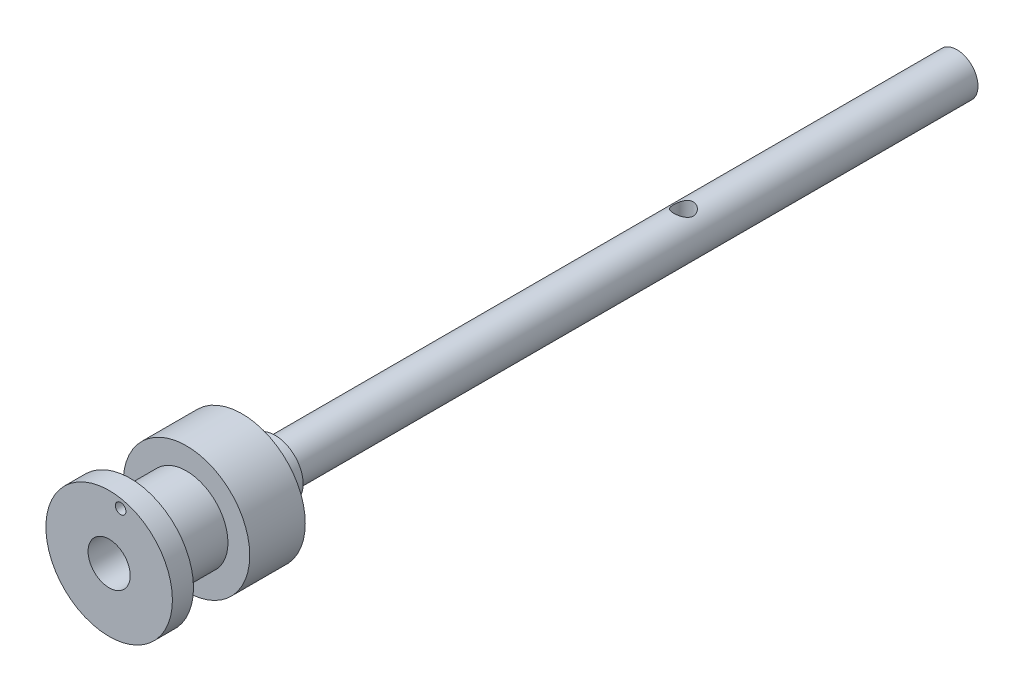
from build123d import *

# Parameters (mm, degrees)
SKETCH1_R               = 3
BOSS_EXTRUDE1_DEPTH     = 97
SKETCH2_R               = 4
BOSS_EXTRUDE2_DEPTH     = 4.7
SKETCH3_R               = 9
BOSS_EXTRUDE3_DEPTH     = 7.9
SKETCH4_R               = 5.9
BOSS_EXTRUDE4_DEPTH     = 8
SKETCH5_R               = 9
BOSS_EXTRUDE5_DEPTH     = 3
CUT_EXTRUDE1_DEPTH      = 82
CUT_EXTRUDE1_DEPTH_BACK = 82
SKETCH6_R               = 1.4
CUT_EXTRUDE2_START      = -9
SKETCH7_R               = 3
SKETCH7_R_2             = 0.75
CUT_EXTRUDE2_DEPTH      = 9


with BuildPart() as part:
    # Sketch1 → Boss-Extrude1 (new body)
    with BuildSketch(Plane.XY):
        Circle(SKETCH1_R)
    extrude(amount=BOSS_EXTRUDE1_DEPTH)

    # Sketch2 → Boss-Extrude2 (add)
    with BuildSketch(Plane.XY.offset(97)):
        Circle(SKETCH2_R)
    extrude(amount=BOSS_EXTRUDE2_DEPTH)

    # Sketch3 → Boss-Extrude3 (add)
    with BuildSketch(Plane.XY.offset(101.7)):
        Circle(SKETCH3_R)
    extrude(amount=BOSS_EXTRUDE3_DEPTH)

    # Sketch4 → Boss-Extrude4 (add)
    with BuildSketch(Plane.XY.offset(109.6)):
        Circle(SKETCH4_R)
    extrude(amount=BOSS_EXTRUDE4_DEPTH)

    # Sketch5 → Boss-Extrude5 (add)
    with BuildSketch(Plane.XY.offset(117.6)):
        Circle(SKETCH5_R)
    extrude(amount=BOSS_EXTRUDE5_DEPTH)

    # Sketch6 → Cut-Extrude1 (cut, two sides: drawn at the far end of the back side and taken through both)
    with BuildSketch(Plane(origin=(0, 0, 0), x_dir=(1, 0, 0), z_dir=(0, 1, 0)).offset(-CUT_EXTRUDE1_DEPTH_BACK)):
        with Locations((0, -38.9)):
            Circle(SKETCH6_R)
    extrude(amount=CUT_EXTRUDE1_DEPTH + CUT_EXTRUDE1_DEPTH_BACK, mode=Mode.SUBTRACT)

    # Sketch7 → Cut-Extrude2 (cut)
    with BuildSketch(Plane.XY.offset(120.6).offset(CUT_EXTRUDE2_START)):
        Circle(SKETCH7_R)
        with Locations((1.637751338, 7.588247864)):
            Circle(SKETCH7_R_2)
    extrude(amount=CUT_EXTRUDE2_DEPTH, mode=Mode.SUBTRACT)


solid = part.part
